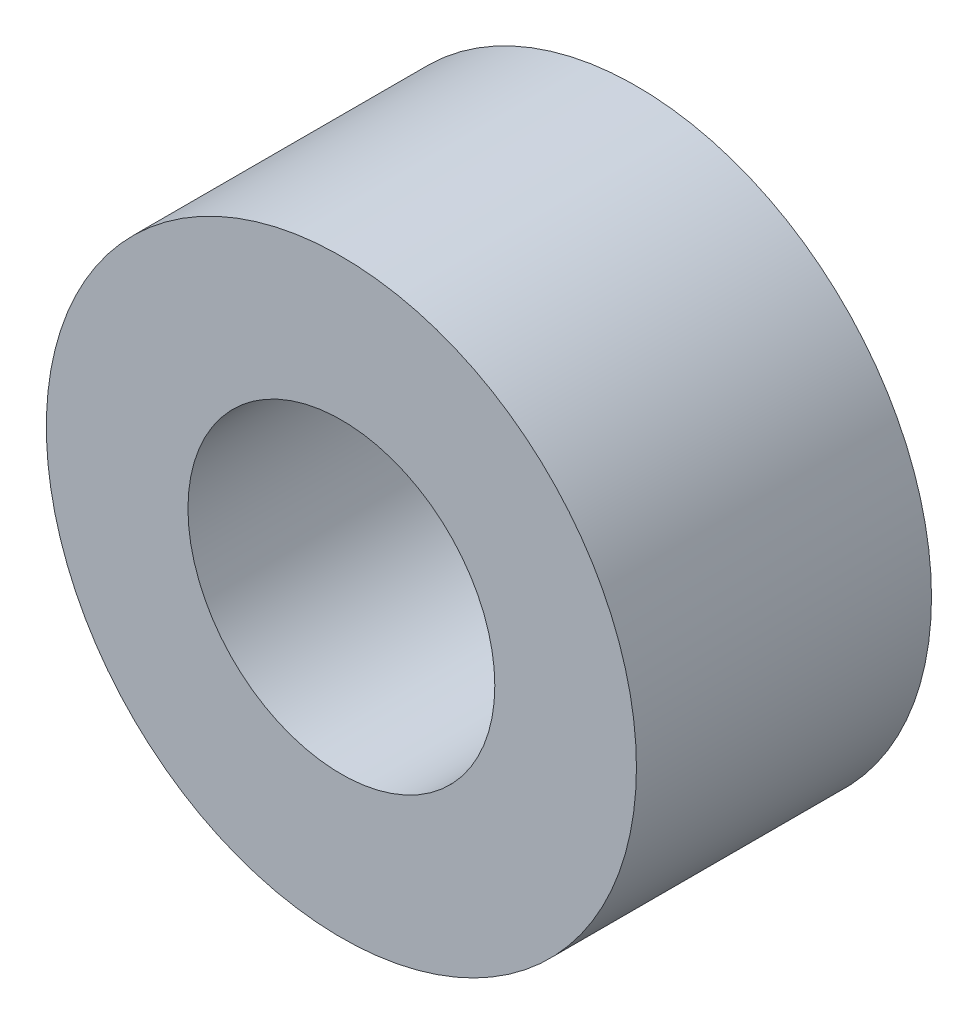
from build123d import *

# Parameters (mm, degrees)
SKETCH1_R           = 6.35
BOSS_EXTRUDE1_DEPTH = 6.35
SKETCH2_R           = 3.302
CUT_EXTRUDE1_DEPTH  = 7.35


with BuildPart() as part:
    # Sketch1 → Boss-Extrude1 (new body)
    with BuildSketch(Plane.XY):
        Circle(SKETCH1_R)
    extrude(amount=BOSS_EXTRUDE1_DEPTH)

    # Sketch2 → Cut-Extrude1 (cut, through all)
    with BuildSketch(Plane.XY.offset(6.35)):
        Circle(SKETCH2_R)
    extrude(amount=-CUT_EXTRUDE1_DEPTH, mode=Mode.SUBTRACT)


solid = part.part
